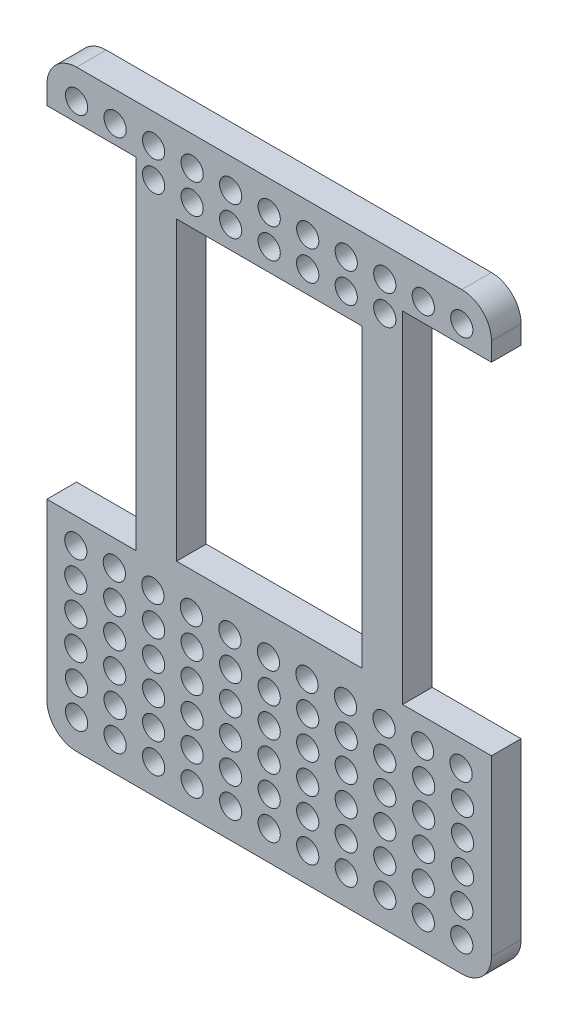
from build123d import *

# Parameters (mm, degrees)
EXTRUDE_1_DEPTH     = 4
SKETCH_3_R          = 1.5
CUT_EXTRUDE_2_DEPTH = 4
SKETCH_5_W          = 12
SKETCH_5_H          = 46
CUT_EXTRUDE_3_DEPTH = 10
SKETCH_6_W          = 25
SKETCH_6_H          = 40
CUT_EXTRUDE_4_DEPTH = 10


with BuildPart() as part:
    # Эскиз1 → Бобышка-Вытянуть1 (new body)
    with BuildSketch(Plane.XY):
        with BuildLine():
            Line((4, 0), (56, 0))
            ThreePointArc((56, 0), (58.828427125, 1.171572875), (60, 4))
            Line((60, 4), (60, 76))
            ThreePointArc((60, 76), (58.828427125, 78.828427125), (56, 80))
            Line((56, 80), (4, 80))
            ThreePointArc((4, 80), (1.171572875, 78.828427125), (0, 76))
            Line((0, 76), (0, 4))
            ThreePointArc((0, 4), (1.171572875, 1.171572875), (4, 0))
        make_face()
    extrude(amount=EXTRUDE_1_DEPTH)

    # Эскиз3 → Вырез-Вытянуть2 (cut)
    with BuildSketch(Plane.XY.offset(4)):
        with Locations((4, 76)):
            Circle(SKETCH_3_R)
        with Locations((9.2, 76)):
            Circle(SKETCH_3_R)
        with Locations((14.4, 76)):
            Circle(SKETCH_3_R)
        with Locations((19.6, 76)):
            Circle(SKETCH_3_R)
        with Locations((24.8, 76)):
            Circle(SKETCH_3_R)
        with Locations((30, 76)):
            Circle(SKETCH_3_R)
        with Locations((35.2, 76)):
            Circle(SKETCH_3_R)
        with Locations((40.4, 76)):
            Circle(SKETCH_3_R)
        with Locations((45.6, 76)):
            Circle(SKETCH_3_R)
        with Locations((50.8, 76)):
            Circle(SKETCH_3_R)
        with Locations((56, 76)):
            Circle(SKETCH_3_R)
        with Locations((14.4, 72)):
            Circle(SKETCH_3_R)
        with Locations((19.6, 72)):
            Circle(SKETCH_3_R)
        with Locations((24.8, 72)):
            Circle(SKETCH_3_R)
        with Locations((30, 72)):
            Circle(SKETCH_3_R)
        with Locations((35.2, 72)):
            Circle(SKETCH_3_R)
        with Locations((40.4, 72)):
            Circle(SKETCH_3_R)
        with Locations((45.6, 72)):
            Circle(SKETCH_3_R)
        with Locations((14.4, 20)):
            Circle(SKETCH_3_R)
        with Locations((19.6, 20)):
            Circle(SKETCH_3_R)
        with Locations((24.8, 20)):
            Circle(SKETCH_3_R)
        with Locations((30, 20)):
            Circle(SKETCH_3_R)
        with Locations((35.2, 20)):
            Circle(SKETCH_3_R)
        with Locations((40.4, 20)):
            Circle(SKETCH_3_R)
        with Locations((45.6, 20)):
            Circle(SKETCH_3_R)
        with Locations((14.4, 16)):
            Circle(SKETCH_3_R)
        with Locations((19.6, 16)):
            Circle(SKETCH_3_R)
        with Locations((24.8, 16)):
            Circle(SKETCH_3_R)
        with Locations((30, 16)):
            Circle(SKETCH_3_R)
        with Locations((35.2, 16)):
            Circle(SKETCH_3_R)
        with Locations((40.4, 16)):
            Circle(SKETCH_3_R)
        with Locations((45.6, 16)):
            Circle(SKETCH_3_R)
        with Locations((14.4, 12)):
            Circle(SKETCH_3_R)
        with Locations((19.6, 12)):
            Circle(SKETCH_3_R)
        with Locations((24.8, 12)):
            Circle(SKETCH_3_R)
        with Locations((30, 12)):
            Circle(SKETCH_3_R)
        with Locations((35.2, 12)):
            Circle(SKETCH_3_R)
        with Locations((40.4, 12)):
            Circle(SKETCH_3_R)
        with Locations((45.6, 12)):
            Circle(SKETCH_3_R)
        with Locations((4, 8)):
            Circle(SKETCH_3_R)
        with Locations((9.2, 8)):
            Circle(SKETCH_3_R)
        with Locations((14.4, 8)):
            Circle(SKETCH_3_R)
        with Locations((19.6, 8)):
            Circle(SKETCH_3_R)
        with Locations((24.8, 8)):
            Circle(SKETCH_3_R)
        with Locations((30, 8)):
            Circle(SKETCH_3_R)
        with Locations((35.2, 8)):
            Circle(SKETCH_3_R)
        with Locations((40.4, 8)):
            Circle(SKETCH_3_R)
        with Locations((45.6, 8)):
            Circle(SKETCH_3_R)
        with Locations((50.8, 8)):
            Circle(SKETCH_3_R)
        with Locations((56, 8)):
            Circle(SKETCH_3_R)
        with Locations((4, 4)):
            Circle(SKETCH_3_R)
        with Locations((9.2, 4)):
            Circle(SKETCH_3_R)
        with Locations((14.4, 4)):
            Circle(SKETCH_3_R)
        with Locations((19.6, 4)):
            Circle(SKETCH_3_R)
        with Locations((24.8, 4)):
            Circle(SKETCH_3_R)
        with Locations((30, 4)):
            Circle(SKETCH_3_R)
        with Locations((35.2, 4)):
            Circle(SKETCH_3_R)
        with Locations((40.4, 4)):
            Circle(SKETCH_3_R)
        with Locations((45.6, 4)):
            Circle(SKETCH_3_R)
        with Locations((50.8, 4)):
            Circle(SKETCH_3_R)
        with Locations((56, 4)):
            Circle(SKETCH_3_R)
        with Locations((50.85, 20)):
            Circle(SKETCH_3_R)
        with Locations((50.85, 16)):
            Circle(SKETCH_3_R)
        with Locations((50.85, 12)):
            Circle(SKETCH_3_R)
        with Locations((56.1, 20)):
            Circle(SKETCH_3_R)
        with Locations((56.1, 16)):
            Circle(SKETCH_3_R)
        with Locations((56.1, 12)):
            Circle(SKETCH_3_R)
        with Locations((3.9, 20)):
            Circle(SKETCH_3_R)
        with Locations((3.9, 16)):
            Circle(SKETCH_3_R)
        with Locations((3.9, 12)):
            Circle(SKETCH_3_R)
        with Locations((9.15, 12)):
            Circle(SKETCH_3_R)
        with Locations((9.15, 16)):
            Circle(SKETCH_3_R)
        with Locations((9.15, 20)):
            Circle(SKETCH_3_R)
        with Locations((3.9, 24)):
            Circle(SKETCH_3_R)
        with Locations((9.1, 24)):
            Circle(SKETCH_3_R)
        with Locations((14.3, 24)):
            Circle(SKETCH_3_R)
        with Locations((19.5, 24)):
            Circle(SKETCH_3_R)
        with Locations((24.7, 24)):
            Circle(SKETCH_3_R)
        with Locations((29.9, 24)):
            Circle(SKETCH_3_R)
        with Locations((35.1, 24)):
            Circle(SKETCH_3_R)
        with Locations((40.3, 24)):
            Circle(SKETCH_3_R)
        with Locations((45.5, 24)):
            Circle(SKETCH_3_R)
        with Locations((50.7, 24)):
            Circle(SKETCH_3_R)
        with Locations((55.9, 24)):
            Circle(SKETCH_3_R)
    extrude(amount=-CUT_EXTRUDE_2_DEPTH, mode=Mode.SUBTRACT)

    # Эскиз5 → Вырез-Вытянуть3 (cut)
    with BuildSketch(Plane.XY.offset(4)):
        with Locations((6, 50.5)):
            Rectangle(SKETCH_5_W, SKETCH_5_H)
        with Locations((54, 50.5)):
            Rectangle(SKETCH_5_W, SKETCH_5_H)
    extrude(amount=-CUT_EXTRUDE_3_DEPTH, mode=Mode.SUBTRACT)

    # Эскиз6 → Вырез-Вытянуть4 (cut)
    with BuildSketch(Plane.XY.offset(4)):
        with Locations((30, 49)):
            Rectangle(SKETCH_6_W, SKETCH_6_H)
    extrude(amount=-CUT_EXTRUDE_4_DEPTH, mode=Mode.SUBTRACT)


solid = part.part
